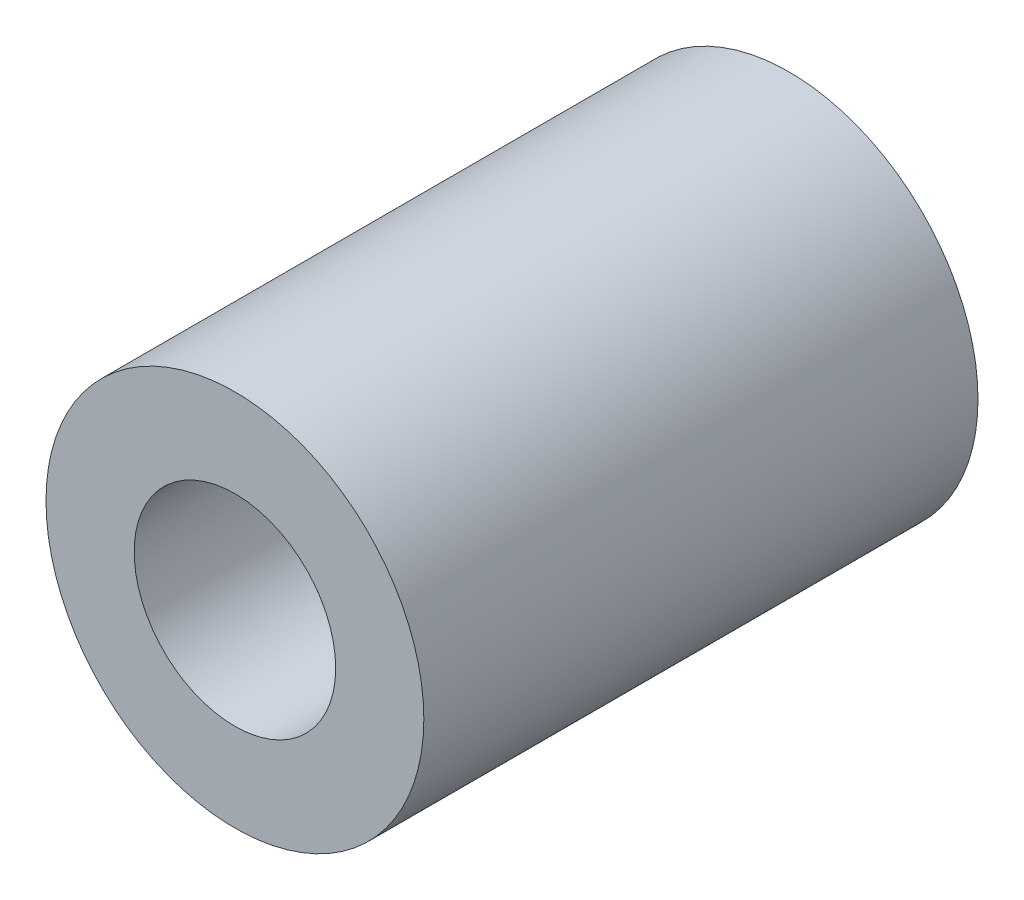
from build123d import *

# Parameters (mm, degrees)
ESQUISSE1_R        = 7.5
ESQUISSE1_R_2      = 4
BOSS_EXTRU_1_DEPTH = 22


with BuildPart() as part:
    # Esquisse1 → Boss.-Extru.1 (new body)
    with BuildSketch(Plane.XY):
        Circle(ESQUISSE1_R)
        Circle(ESQUISSE1_R_2, mode=Mode.SUBTRACT)
    extrude(amount=BOSS_EXTRU_1_DEPTH)


solid = part.part
